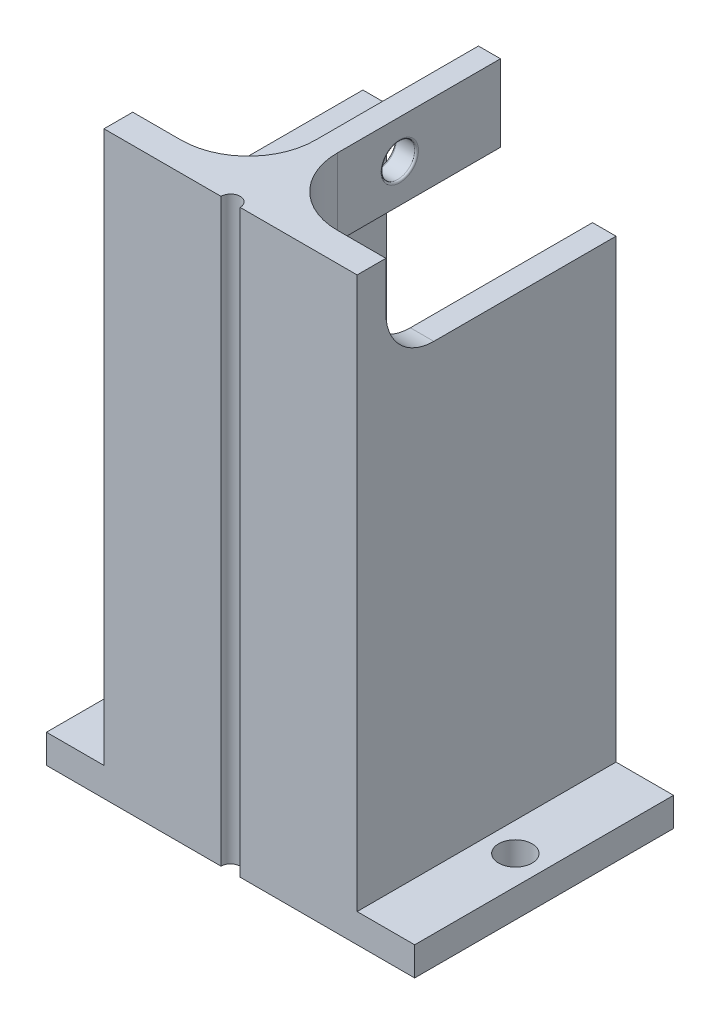
from build123d import *

# Parameters (mm, degrees)
SKETCH_1_W          = 26.4
SKETCH_1_H          = 60.5
EXTRUDE_1_DEPTH     = 27
SKETCH_3_W          = 21.5
SKETCH_3_H          = 60.5
CUT_EXTRUDE_1_DEPTH = 24
SKETCH_4_W          = 24
SKETCH_4_H          = 10
CUT_EXTRUDE_2_DEPTH = 27.4
SKETCH_7_W          = 2.3
SKETCH_7_H          = 8
EXTRUDE_3_DEPTH     = 24
CUT_EXTRUDE_4_REACH = 16.35
SKETCH_9_R          = 1.75
FILLET_1_R          = 7
FILLET_2_R          = 7
FILLET_3_R          = 4
FILLET_4_R          = 0.2
FILLET_7_R          = 5
SKETCH_10_R         = 1
CUT_EXTRUDE_5_DEPTH = 61.5000001
SKETCH_11_W         = 6
SKETCH_11_H         = 27
SKETCH_11_R         = 1.75
EXTRUDE_4_DEPTH     = 3


with BuildPart() as part:
    # ｽｹｯﾁ1 → ﾎﾞｽ - 押し出し1 (new body)
    with BuildSketch(Plane.XY):
        Rectangle(SKETCH_1_W, SKETCH_1_H)
    extrude(amount=EXTRUDE_1_DEPTH)

    # ｽｹｯﾁ3 → ｶｯﾄ - 押し出し1 (cut)
    with BuildSketch(Plane(origin=(0, 0, 0), x_dir=(-1, 0, 0), z_dir=(0, 0, -1))):
        Rectangle(SKETCH_3_W, SKETCH_3_H)
    extrude(amount=-CUT_EXTRUDE_1_DEPTH, mode=Mode.SUBTRACT)

    # ｽｹｯﾁ4 → ｶｯﾄ - 押し出し2 (cut, through all)
    with BuildSketch(Plane.ZY.offset(13.2)):
        with Locations((12, 25.25)):
            Rectangle(SKETCH_4_W, SKETCH_4_H)
    extrude(amount=-CUT_EXTRUDE_2_DEPTH, mode=Mode.SUBTRACT)

    # ｽｹｯﾁ7 → ﾎﾞｽ - 押し出し3 (add)
    with BuildSketch(Plane(origin=(0, 0, 24), x_dir=(-1, 0, 0), z_dir=(0, 0, -1))):
        with Locations((0, 26.25)):
            Rectangle(SKETCH_7_W, SKETCH_7_H)
    extrude(amount=EXTRUDE_3_DEPTH)

    # ｽｹｯﾁ9 → ｶｯﾄ - 押し出し4 (cut, up to next)
    with BuildSketch(Plane(origin=(1.15, 0, 0), x_dir=(0, 0, -1), z_dir=(1, 0, 0)), mode=Mode.PRIVATE) as cut_extrude_4_sk1:
        with Locations((-10.5, 26.25)):
            Circle(SKETCH_9_R)
    cut_extrude_4_tool1 = extrude(cut_extrude_4_sk1.sketch, amount=-CUT_EXTRUDE_4_REACH, mode=Mode.PRIVATE) & part.part
    add(cut_extrude_4_tool1.solids().sort_by_distance((1.15, 26.25, 10.5))[0], mode=Mode.SUBTRACT)

    # ﾌｨﾚｯﾄ1
    fillet_1_edges = [part.edges().sort_by_distance(p)[0] for p in [
        (1.15, 26.25, 24),
    ]]
    fillet(fillet_1_edges, radius=FILLET_1_R)

    # ﾌｨﾚｯﾄ2
    fillet_2_edges = [part.edges().sort_by_distance(p)[0] for p in [
        (-1.15, 26.25, 24),
    ]]
    fillet(fillet_2_edges, radius=FILLET_2_R)

    # ﾌｨﾚｯﾄ3
    fillet_3_edges = [part.edges().sort_by_distance(p)[0] for p in [
        (0, 22.25, 24),
    ]]
    fillet(fillet_3_edges, radius=FILLET_3_R)

    # ﾌｨﾚｯﾄ4
    fillet_4_edges = [part.edges().sort_by_distance(p)[0] for p in [
        (1.15, 26.25, 12.25),
        (-1.15, 26.25, 12.25),
    ]]
    fillet(fillet_4_edges, radius=FILLET_4_R)

    # ﾌｨﾚｯﾄ7
    fillet_7_edges = [part.edges().sort_by_distance(p)[0] for p in [
        (11.975, 20.25, 24),
        (-11.975, 20.25, 24),
    ]]
    fillet(fillet_7_edges, radius=FILLET_7_R)

    # ｽｹｯﾁ10 → ｶｯﾄ - 押し出し5 (cut, through all)
    with BuildSketch(Plane(origin=(0, -30.25, 0), x_dir=(-1, 0, 0), z_dir=(0, -1, 0))):
        with Locations((0, -27)):
            Circle(SKETCH_10_R)
    extrude(amount=-CUT_EXTRUDE_5_DEPTH, mode=Mode.SUBTRACT)

    # ｽｹｯﾁ11 → ﾎﾞｽ - 押し出し4 (add)
    with BuildSketch(Plane(origin=(0, -30.25, 0), x_dir=(-1, 0, 0), z_dir=(0, -1, 0))):
        with Locations((-16.2, -13.5)):
            Rectangle(SKETCH_11_W, SKETCH_11_H)
        with Locations((-16.2, -13.5)):
            Circle(SKETCH_11_R, mode=Mode.SUBTRACT)
        with Locations((16.2, -13.5)):
            Rectangle(SKETCH_11_W, SKETCH_11_H)
        with Locations((16.2, -13.5)):
            Circle(SKETCH_11_R, mode=Mode.SUBTRACT)
    extrude(amount=-EXTRUDE_4_DEPTH)


solid = part.part
